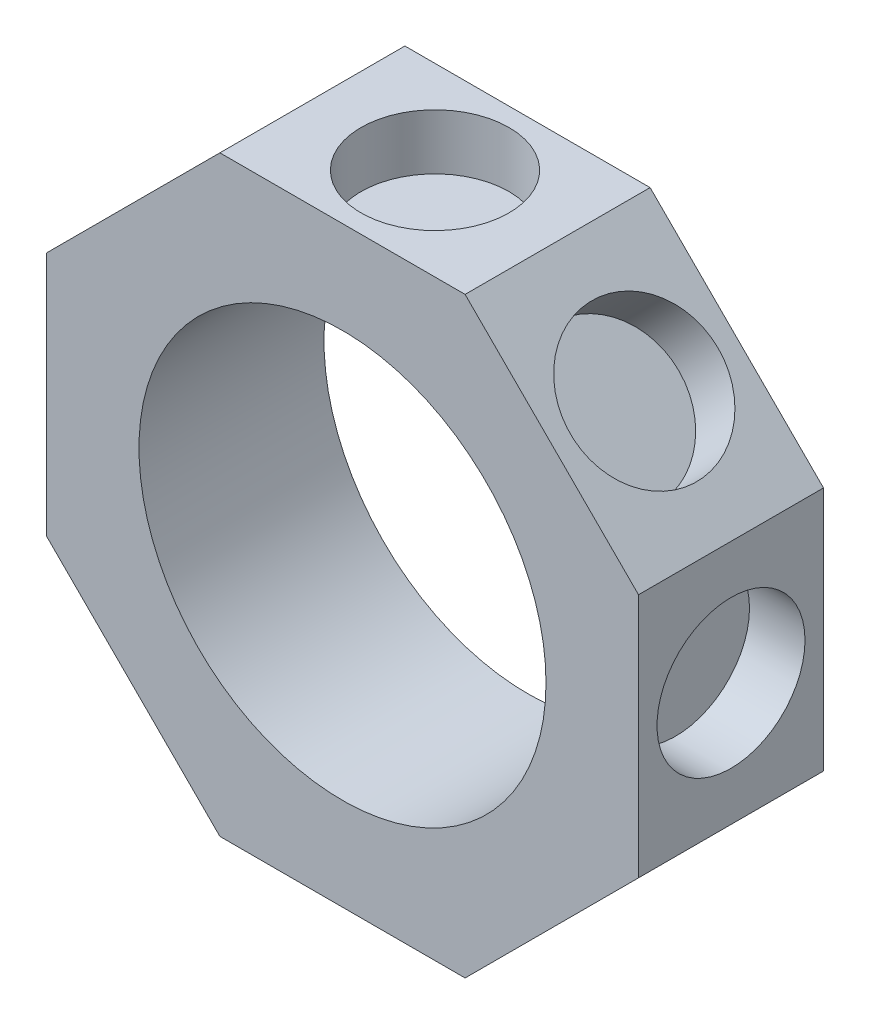
from build123d import *

# Parameters (mm, degrees)
SKETCH1_R           = 11
BOSS_EXTRUDE1_DEPTH = 5
SKETCH2_R           = 4
CUT_EXTRUDE3_DEPTH  = 3
CIRPATTERN1_COUNT   = 8


with BuildPart() as part:
    # Sketch1 → Boss-Extrude1 (new, symmetric)
    with BuildSketch(Plane.XY):
        Polygon((6.627416998, 16), (-6.627416998, 16), (-16, 6.627416998), (-16, -6.627416998), (-6.627416998, -16), (6.627416998, -16), (16, -6.627416998), (16, 6.627416998), align=None)
        Circle(SKETCH1_R, mode=Mode.SUBTRACT)
    extrude(amount=BOSS_EXTRUDE1_DEPTH, both=True)

    # Sketch2 → Cut-Extrude3 (cut)
    with BuildSketch(Plane(origin=(0, -16, 0), x_dir=(-1, 0, 0), z_dir=(0, -1, 0))):
        Circle(SKETCH2_R)
    cut_extrude3 = extrude(amount=-CUT_EXTRUDE3_DEPTH, mode=Mode.SUBTRACT)

    # CirPattern1: Cut-Extrude3 ×8 about axis
    cirpattern1_axis = Axis((0, 0, 5), (0, 0, 1))
    for i in range(1, CIRPATTERN1_COUNT):
        add(cut_extrude3.rotate(cirpattern1_axis, i * 360 / CIRPATTERN1_COUNT), mode=Mode.SUBTRACT)


solid = part.part
